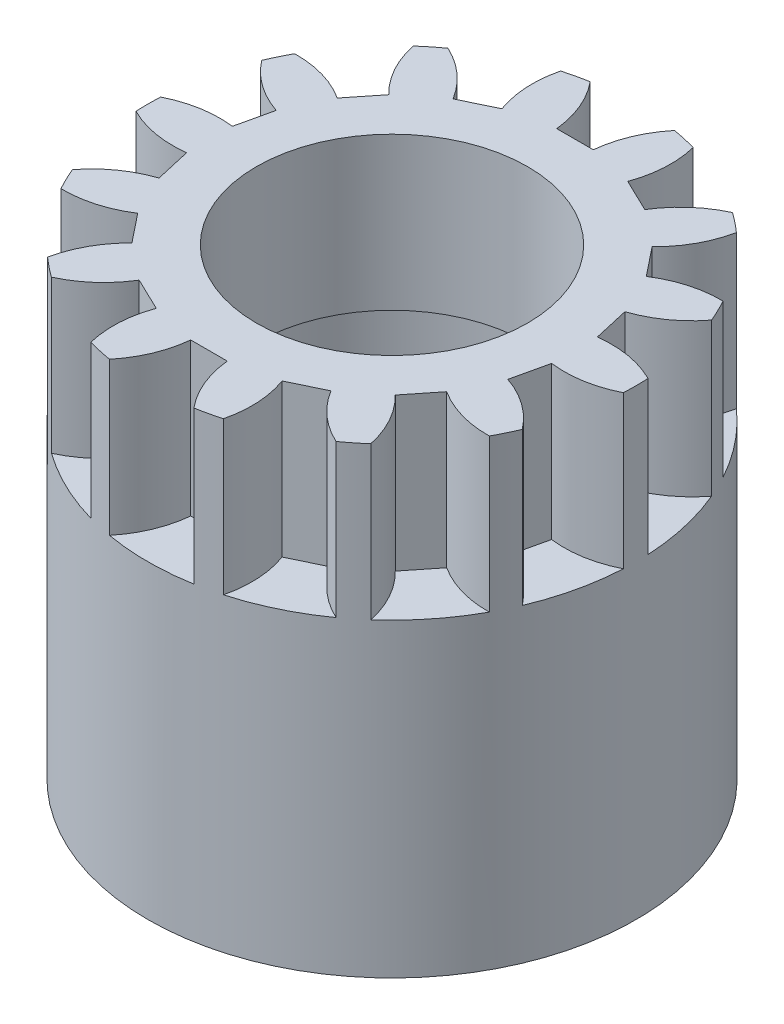
from build123d import *

# Parameters (mm, degrees)
SKETCH3_R           = 8
BOSS_EXTRUDE3_DEPTH = 5
CUT_EXTRUDE1_DEPTH  = 5
SKETCH6_R           = 4.445
CUT_EXTRUDE2_DEPTH  = 6
SKETCH8_R           = 8
SKETCH8_R_2         = 5.08
BOSS_EXTRUDE4_DEPTH = 10.16


with BuildPart() as part:
    # Sketch3 → Boss-Extrude3 (new body)
    with BuildSketch(Plane(origin=(0, 0, 0), x_dir=(1, 0, 0), z_dir=(0, 1, 0))):
        Circle(SKETCH3_R)
    extrude(amount=BOSS_EXTRUDE3_DEPTH)

    # Sketch4 → Cut-Extrude1 (cut)
    with BuildSketch(Plane(origin=(0, 5, 0), x_dir=(1, 0, 0), z_dir=(0, 1, 0))):
        with BuildLine():
            Line((-0.5999988, 6), (0.5999988, 6))
            ThreePointArc((0.5999988, 6), (0.85189286, 6.99797085), (1.383185318, 7.879517649))
            ThreePointArc((1.383185318, 7.879517649), (0, 8), (-1.383185318, 7.879517649))
            ThreePointArc((-1.383185318, 7.879517649), (-0.85189286, 6.99797085), (-0.5999988, 6))
        make_face()
        with BuildLine():
            Line((2.062722195, 5.66614293), (3.143882674, 5.145483485))
            ThreePointArc((3.143882674, 5.145483485), (3.803834704, 5.935331415), (4.66500149, 6.499058478))
            ThreePointArc((4.66500149, 6.499058478), (3.471069913, 7.207750943), (2.17258767, 7.699341713))
            ThreePointArc((2.17258767, 7.699341713), (2.268776813, 6.674576334), (2.062722195, 5.66614293))
        make_face()
        with BuildLine():
            Line((4.316895762, 4.210036762), (5.065082028, 3.27184086))
            ThreePointArc((5.065082028, 3.27184086), (6.002380434, 3.697126801), (7.022856904, 3.83138107))
            ThreePointArc((7.022856904, 3.83138107), (6.25465186, 4.987918415), (5.298053025, 5.994216725))
            ThreePointArc((5.298053025, 5.994216725), (4.940087414, 5.029200116), (4.316895762, 4.210036762))
        make_face()
        with BuildLine():
            Line((5.71605518, 1.920081181), (5.983079766, 0.750170026))
            ThreePointArc((5.983079766, 0.750170026), (7.012081105, 0.726660882), (7.989749379, 0.404851652))
            ThreePointArc((7.989749379, 0.404851652), (7.799423297, 1.780167472), (7.374174001, 3.1018636))
            ThreePointArc((7.374174001, 3.1018636), (6.632953116, 2.387729136), (5.71605518, 1.920081181))
        make_face()
        with BuildLine():
            Line((5.983079766, -0.750170026), (5.71605518, -1.920081181))
            ThreePointArc((5.71605518, -1.920081181), (6.632953116, -2.387729136), (7.374174001, -3.1018636))
            ThreePointArc((7.374174001, -3.1018636), (7.799423297, -1.780167472), (7.989749379, -0.404851652))
            ThreePointArc((7.989749379, -0.404851652), (7.012081105, -0.726660882), (5.983079766, -0.750170026))
        make_face()
        with BuildLine():
            Line((5.065082028, -3.27184086), (4.316895762, -4.210036762))
            ThreePointArc((4.316895762, -4.210036762), (4.940087414, -5.029200116), (5.298053025, -5.994216725))
            ThreePointArc((5.298053025, -5.994216725), (6.25465186, -4.987918415), (7.022856904, -3.83138107))
            ThreePointArc((7.022856904, -3.83138107), (6.002380434, -3.697126801), (5.065082028, -3.27184086))
        make_face()
        with BuildLine():
            Line((3.143882674, -5.145483485), (2.062722195, -5.66614293))
            ThreePointArc((2.062722195, -5.66614293), (2.268776813, -6.674576334), (2.17258767, -7.699341713))
            ThreePointArc((2.17258767, -7.699341713), (3.471069913, -7.207750943), (4.66500149, -6.499058478))
            ThreePointArc((4.66500149, -6.499058478), (3.803834704, -5.935331415), (3.143882674, -5.145483485))
        make_face()
        with BuildLine():
            Line((0.5999988, -6), (-0.5999988, -6))
            ThreePointArc((-0.5999988, -6), (-0.85189286, -6.99797085), (-1.383185318, -7.879517649))
            ThreePointArc((-1.383185318, -7.879517649), (0, -8), (1.383185318, -7.879517649))
            ThreePointArc((1.383185318, -7.879517649), (0.85189286, -6.99797085), (0.5999988, -6))
        make_face()
        with BuildLine():
            Line((-2.062722195, -5.66614293), (-3.143882674, -5.145483485))
            ThreePointArc((-3.143882674, -5.145483485), (-3.803834704, -5.935331415), (-4.66500149, -6.499058478))
            ThreePointArc((-4.66500149, -6.499058478), (-3.471069913, -7.207750943), (-2.17258767, -7.699341713))
            ThreePointArc((-2.17258767, -7.699341713), (-2.268776813, -6.674576334), (-2.062722195, -5.66614293))
        make_face()
        with BuildLine():
            Line((-4.316895762, -4.210036762), (-5.065082028, -3.27184086))
            ThreePointArc((-5.065082028, -3.27184086), (-6.002380434, -3.697126801), (-7.022856904, -3.83138107))
            ThreePointArc((-7.022856904, -3.83138107), (-6.25465186, -4.987918415), (-5.298053025, -5.994216725))
            ThreePointArc((-5.298053025, -5.994216725), (-4.940087414, -5.029200116), (-4.316895762, -4.210036762))
        make_face()
        with BuildLine():
            Line((-5.71605518, -1.920081181), (-5.983079766, -0.750170026))
            ThreePointArc((-5.983079766, -0.750170026), (-7.012081105, -0.726660882), (-7.989749379, -0.404851652))
            ThreePointArc((-7.989749379, -0.404851652), (-7.799423297, -1.780167472), (-7.374174001, -3.1018636))
            ThreePointArc((-7.374174001, -3.1018636), (-6.632953116, -2.387729136), (-5.71605518, -1.920081181))
        make_face()
        with BuildLine():
            Line((-5.983079766, 0.750170026), (-5.71605518, 1.920081181))
            ThreePointArc((-5.71605518, 1.920081181), (-6.632953116, 2.387729136), (-7.374174001, 3.1018636))
            ThreePointArc((-7.374174001, 3.1018636), (-7.799423297, 1.780167472), (-7.989749379, 0.404851652))
            ThreePointArc((-7.989749379, 0.404851652), (-7.012081105, 0.726660882), (-5.983079766, 0.750170026))
        make_face()
        with BuildLine():
            Line((-5.065082028, 3.27184086), (-4.316895762, 4.210036762))
            ThreePointArc((-4.316895762, 4.210036762), (-4.940087414, 5.029200116), (-5.298053025, 5.994216725))
            ThreePointArc((-5.298053025, 5.994216725), (-6.25465186, 4.987918415), (-7.022856904, 3.83138107))
            ThreePointArc((-7.022856904, 3.83138107), (-6.002380434, 3.697126801), (-5.065082028, 3.27184086))
        make_face()
        with BuildLine():
            Line((-3.143882674, 5.145483485), (-2.062722195, 5.66614293))
            ThreePointArc((-2.062722195, 5.66614293), (-2.268776813, 6.674576334), (-2.17258767, 7.699341713))
            ThreePointArc((-2.17258767, 7.699341713), (-3.471069913, 7.207750943), (-4.66500149, 6.499058478))
            ThreePointArc((-4.66500149, 6.499058478), (-3.803834704, 5.935331415), (-3.143882674, 5.145483485))
        make_face()
    extrude(amount=-CUT_EXTRUDE1_DEPTH, mode=Mode.SUBTRACT)

    # Sketch6 → Cut-Extrude2 (cut, through all)
    with BuildSketch(Plane(origin=(0, 5, 0), x_dir=(1, 0, 0), z_dir=(0, 1, 0))):
        Circle(SKETCH6_R)
    extrude(amount=-CUT_EXTRUDE2_DEPTH, mode=Mode.SUBTRACT)

    # Sketch8 → Boss-Extrude4 (add)
    with BuildSketch(Plane.XZ):
        Circle(SKETCH8_R)
        Circle(SKETCH8_R_2, mode=Mode.SUBTRACT)
    extrude(amount=BOSS_EXTRUDE4_DEPTH)


solid = part.part
